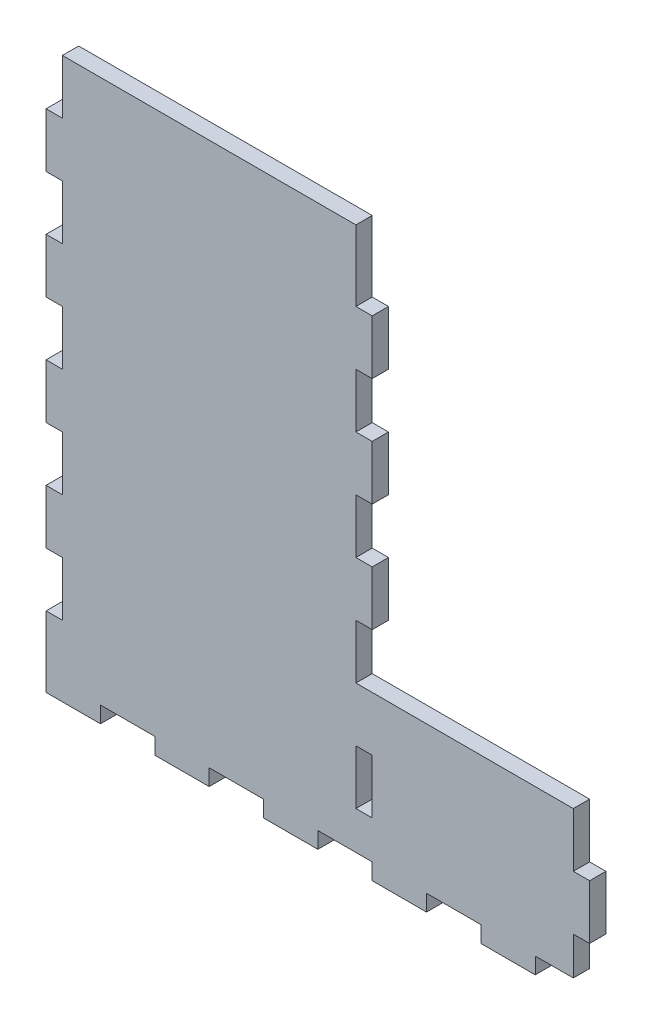
from build123d import *

# Parameters (mm, degrees)
BOSS_EXTRUDE1_DEPTH = 6
SKETCH2_W           = 20
SKETCH2_H           = 6
CUT_EXTRUDE1_DEPTH  = 7
LPATTERN1_COUNT     = 5
LPATTERN1_PITCH     = 40
SKETCH3_W           = 6
SKETCH3_H           = 20
CUT_EXTRUDE2_DEPTH  = 7
LPATTERN2_COUNT     = 5
LPATTERN2_PITCH     = 40
SKETCH4_W           = 6
SKETCH4_H           = 6
CUT_EXTRUDE3_DEPTH  = 10
SKETCH5_W           = 6
SKETCH5_H           = 20
CUT_EXTRUDE4_DEPTH  = 10
LPATTERN3_COUNT     = 2
LPATTERN3_PITCH     = 40
SKETCH7_W           = 6
SKETCH7_H           = 20
CUT_EXTRUDE5_DEPTH  = 10
LPATTERN4_COUNT     = 5
LPATTERN4_PITCH     = 40


with BuildPart() as part:
    # Sketch1 → Boss-Extrude1 (new body)
    with BuildSketch(Plane.XY):
        Polygon((-17.330934256, 199.427419355), (102.669065744, 199.427419355), (102.669065744, 53.427419355), (182.669065744, 53.427419355), (182.669065744, -6.572580645), (102.669065744, -6.572580645), (-17.330934256, -6.572580645), align=None)
    extrude(amount=BOSS_EXTRUDE1_DEPTH)

    # Sketch2 → Cut-Extrude1 (cut, through all)
    with BuildSketch(Plane.XY.offset(6)):
        with Locations((12.669065744, -3.572580645)):
            Rectangle(SKETCH2_W, SKETCH2_H)
    cut_extrude1 = extrude(amount=-CUT_EXTRUDE1_DEPTH, mode=Mode.SUBTRACT)

    # LPattern1: Cut-Extrude1 ×5
    with Locations(*[(i * LPATTERN1_PITCH, 0, 0) for i in range(1, LPATTERN1_COUNT)]):
        add(cut_extrude1, mode=Mode.SUBTRACT)

    # Sketch3 → Cut-Extrude2 (cut, through all)
    with BuildSketch(Plane.XY):
        with Locations((99.669065744, 23.427419355)):
            Rectangle(SKETCH3_W, SKETCH3_H)
    cut_extrude2 = extrude(amount=CUT_EXTRUDE2_DEPTH, mode=Mode.SUBTRACT)

    # LPattern2: Cut-Extrude2 ×5
    with Locations(*[(0, i * LPATTERN2_PITCH, 0) for i in range(1, LPATTERN2_COUNT)]):
        add(cut_extrude2, mode=Mode.SUBTRACT)

    # Sketch4 → Cut-Extrude3 (cut)
    with BuildSketch(Plane.XY.offset(6)):
        with Locations((99.669065744, 196.427419355)):
            Rectangle(SKETCH4_W, SKETCH4_H)
    extrude(amount=-CUT_EXTRUDE3_DEPTH, mode=Mode.SUBTRACT)

    # Sketch5 → Cut-Extrude4 (cut)
    with BuildSketch(Plane.XY.offset(6)):
        with Locations((179.669065744, 43.427419355)):
            Rectangle(SKETCH5_W, SKETCH5_H)
    cut_extrude4 = extrude(amount=-CUT_EXTRUDE4_DEPTH, mode=Mode.SUBTRACT)

    # LPattern3: Cut-Extrude4 ×2
    with Locations(*[(0, -i * LPATTERN3_PITCH, 0) for i in range(1, LPATTERN3_COUNT)]):
        add(cut_extrude4, mode=Mode.SUBTRACT)

    # Sketch7 → Cut-Extrude5 (cut)
    with BuildSketch(Plane.XY.offset(6)):
        with Locations((-14.330934256, 189.427419355)):
            Rectangle(SKETCH7_W, SKETCH7_H)
    cut_extrude5 = extrude(amount=-CUT_EXTRUDE5_DEPTH, mode=Mode.SUBTRACT)

    # LPattern4: Cut-Extrude5 ×5
    with Locations(*[(0, -i * LPATTERN4_PITCH, 0) for i in range(1, LPATTERN4_COUNT)]):
        add(cut_extrude5, mode=Mode.SUBTRACT)


solid = part.part
